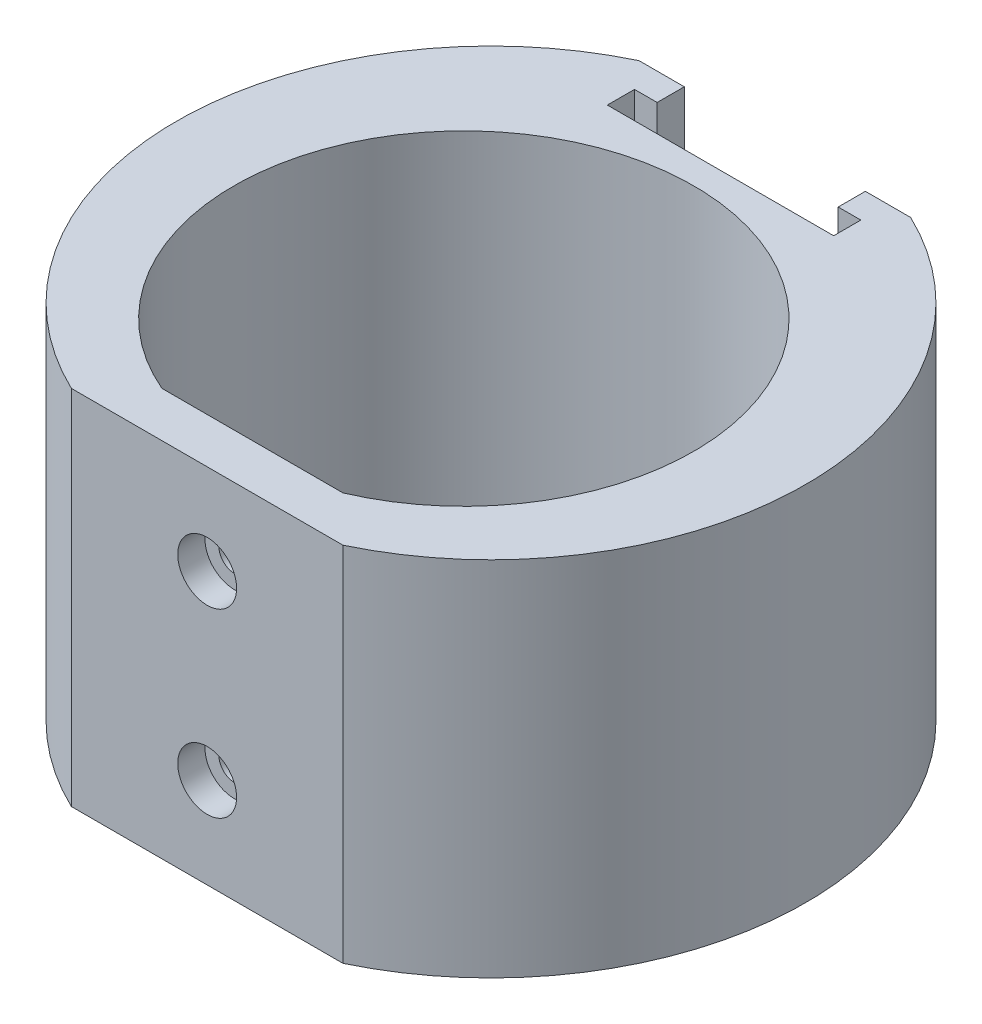
from build123d import *

# Parameters (mm, degrees)
BOSS_EXTRUDE1_DEPTH            = 20
CUT_EXTRUDE1_DEPTH             = 27.5
CBORE_FOR_M3_SHCS1_D           = 3.4
CBORE_FOR_M3_SHCS1_DEPTH       = 5
CBORE_FOR_M3_SHCS1_CBORE_D     = 6.5
CBORE_FOR_M3_SHCS1_CBORE_DEPTH = 3
FILLET1_R                      = 2


with BuildPart() as part:
    # Sketch1 → Boss-Extrude1 (new body, symmetric)
    with BuildSketch(Plane(origin=(0, 0, 0), x_dir=(1, 0, 0), z_dir=(0, 1, 0))):
        with BuildLine():
            Line((-15, -28.348661632), (15, -28.348661632))
            ThreePointArc((15, -28.348661632), (34.752533521, 3), (15, 34.348661632))
            Line((15, 34.348661632), (-15, 34.348661632))
            ThreePointArc((-15, 34.348661632), (-34.752533521, 3), (-15, -28.348661632))
        make_face()
        with BuildLine():
            Line((-10, -23.348661632), (10, -23.348661632))
            ThreePointArc((10, -23.348661632), (0, 25.4), (-10, -23.348661632))
        make_face(mode=Mode.SUBTRACT)
    extrude(amount=BOSS_EXTRUDE1_DEPTH, both=True)

    # Sketch3 → Cut-Extrude1 (cut)
    with BuildSketch(Plane(origin=(0, 20, 0), x_dir=(1, 0, 0), z_dir=(0, 1, 0))):
        Polygon((-10, 34.348661632), (-10, 31.348661632), (-12.5, 31.348661632), (-12.5, 28.348661632), (12.5, 28.348661632), (12.5, 31.348661632), (10, 31.348661632), (10, 34.348661632), align=None)
    extrude(amount=-CUT_EXTRUDE1_DEPTH, mode=Mode.SUBTRACT)

    # CBORE for M3 SHCS1
    with Locations(Plane.XY.offset(28.348661632)):
        with Locations((0, 10), (0, -10)):
            CounterBoreHole(CBORE_FOR_M3_SHCS1_D / 2, CBORE_FOR_M3_SHCS1_CBORE_D / 2, CBORE_FOR_M3_SHCS1_CBORE_DEPTH, depth=CBORE_FOR_M3_SHCS1_DEPTH)

    # Fillet1
    fillet1_edges = [part.edges().sort_by_distance(p)[0] for p in [
        (10, -7.5, -32.848661632),
        (12.5, -7.5, -29.848661632),
        (-12.5, -7.5, -29.848661632),
        (-10, -7.5, -32.848661632),
    ]]
    fillet(fillet1_edges, radius=FILLET1_R)


solid = part.part
